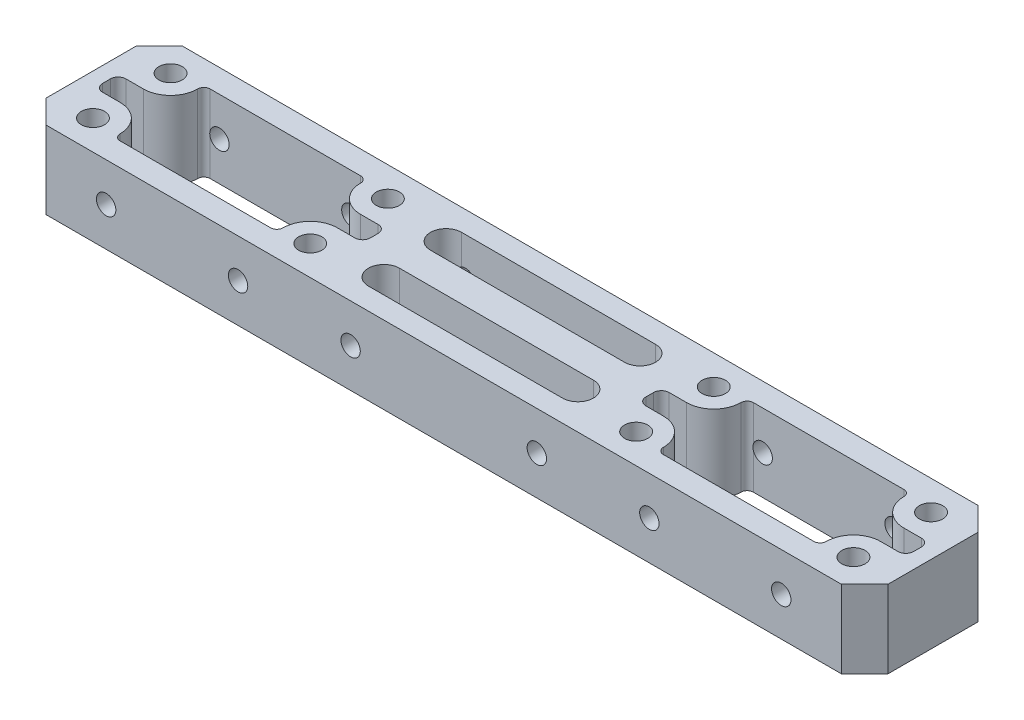
from build123d import *

# Parameters (mm, degrees)
SKETCH_1_W          = 38.5
SKETCH_1_H          = 17.6
SKETCH_1_R          = 1.5
EXTRUDE_1_DEPTH     = 10
CUT_EXTRUDE_1_DEPTH = 11
SKETCH_5_W          = 38.5
SKETCH_5_H          = 17.6
SKETCH_5_R          = 1.5
EXTRUDE_6_DEPTH     = 10
SKETCH_10_W         = 31.5
SKETCH_10_H         = 17.6
EXTRUDE_7_DEPTH     = 10
CUT_EXTRUDE_5_DEPTH = 11
CUT_EXTRUDE_6_DEPTH = 11
CHAMFER_1_SIZE      = 3
CUT_EXTRUDE_8_REACH = 19.6
SKETCH_14_R         = 1.25
CUT_EXTRUDE_9_REACH = 19.6
SKETCH_15_R         = 1.25


with BuildPart() as part:
    # 草图1 → 凸台-拉伸1 (new body)
    with BuildSketch(Plane(origin=(0, 0, 0), x_dir=(1, 0, 0), z_dir=(0, 1, 0))):
        Rectangle(SKETCH_1_W, SKETCH_1_H)
        with Locations((-14, 5)):
            Circle(SKETCH_1_R, mode=Mode.SUBTRACT)
        with Locations((-14, -5)):
            Circle(SKETCH_1_R, mode=Mode.SUBTRACT)
        with Locations((14, -5)):
            Circle(SKETCH_1_R, mode=Mode.SUBTRACT)
        with Locations((14, 5)):
            Circle(SKETCH_1_R, mode=Mode.SUBTRACT)
    extrude(amount=EXTRUDE_1_DEPTH)

    # 草图2 → 切除-拉伸1 (cut, through all)
    with BuildSketch(Plane(origin=(0, 10, 0), x_dir=(1, 0, 0), z_dir=(0, 1, 0))):
        with BuildLine():
            Line((9.7, 5.8), (-9.7, 5.8))
            ThreePointArc((-9.7, 5.8), (-10.265685425, 5.565685425), (-10.5, 5))
            ThreePointArc((-10.5, 5), (-11.525126266, 2.525126266), (-14, 1.5))
            Line((-14, 1.5), (-16.25, 1.5))
            ThreePointArc((-16.25, 1.5), (-16.957106781, 1.207106781), (-17.25, 0.5))
            Line((-17.25, 0.5), (-17.25, -0.5))
            ThreePointArc((-17.25, -0.5), (-16.957106781, -1.207106781), (-16.25, -1.5))
            Line((-16.25, -1.5), (-14, -1.5))
            ThreePointArc((-14, -1.5), (-11.525126266, -2.525126266), (-10.5, -5))
            ThreePointArc((-10.5, -5), (-10.265685425, -5.565685425), (-9.7, -5.8))
            Line((-9.7, -5.8), (9.7, -5.8))
            ThreePointArc((9.7, -5.8), (10.265685425, -5.565685425), (10.5, -5))
            ThreePointArc((10.5, -5), (11.525126266, -2.525126266), (14, -1.5))
            Line((14, -1.5), (16.25, -1.5))
            ThreePointArc((16.25, -1.5), (16.957106781, -1.207106781), (17.25, -0.5))
            Line((17.25, -0.5), (17.25, 0.5))
            ThreePointArc((17.25, 0.5), (16.957106781, 1.207106781), (16.25, 1.5))
            Line((16.25, 1.5), (14, 1.5))
            ThreePointArc((14, 1.5), (11.525126266, 2.525126266), (10.5, 5))
            ThreePointArc((10.5, 5), (10.265685425, 5.565685425), (9.7, 5.8))
        make_face()
    extrude(amount=-CUT_EXTRUDE_1_DEPTH, mode=Mode.SUBTRACT)



with BuildPart() as body_2:
    # 草图5 → 凸台-拉伸6 (new body)
    with BuildSketch(Plane(origin=(0, 10, 0), x_dir=(1, 0, 0), z_dir=(0, 1, 0))):
        with Locations((70, 0)):
            Rectangle(SKETCH_5_W, SKETCH_5_H)
        with Locations((56, 5)):
            Circle(SKETCH_5_R, mode=Mode.SUBTRACT)
        with Locations((84, 5)):
            Circle(SKETCH_5_R, mode=Mode.SUBTRACT)
        with Locations((84, -5)):
            Circle(SKETCH_5_R, mode=Mode.SUBTRACT)
        with Locations((56, -5)):
            Circle(SKETCH_5_R, mode=Mode.SUBTRACT)
    extrude(amount=-EXTRUDE_6_DEPTH)


with BuildPart() as part_1:
    add(part.part)

    add(body_2.part)  # 凸台-拉伸7 merges body 2
    # 草图10 → 凸台-拉伸7 (add)
    with BuildSketch(Plane(origin=(0, 10, 0), x_dir=(1, 0, 0), z_dir=(0, 1, 0))):
        with Locations((35, 0)):
            Rectangle(SKETCH_10_W, SKETCH_10_H)
    extrude(amount=-EXTRUDE_7_DEPTH)

    # 草图11 → 切除-拉伸5 (cut, through all)
    with BuildSketch(Plane(origin=(0, 10, 0), x_dir=(1, 0, 0), z_dir=(0, 1, 0))):
        with BuildLine():
            Line((16.25, 1.5), (14, 1.5))
            ThreePointArc((14, 1.5), (11.525126266, 2.525126266), (10.5, 5))
            ThreePointArc((10.5, 5), (10.265685425, 5.565685425), (9.7, 5.8))
            Line((9.7, 5.8), (-9.7, 5.8))
            ThreePointArc((-9.7, 5.8), (-10.265685425, 5.565685425), (-10.5, 5))
            ThreePointArc((-10.5, 5), (-11.525126266, 2.525126266), (-14, 1.5))
            Line((-14, 1.5), (-16.25, 1.5))
            ThreePointArc((-16.25, 1.5), (-16.957106781, 1.207106781), (-17.25, 0.5))
            Line((-17.25, 0.5), (-17.25, -0.5))
            ThreePointArc((-17.25, -0.5), (-16.957106781, -1.207106781), (-16.25, -1.5))
            Line((-16.25, -1.5), (-14, -1.5))
            ThreePointArc((-14, -1.5), (-11.525126266, -2.525126266), (-10.5, -5))
            ThreePointArc((-10.5, -5), (-10.265685425, -5.565685425), (-9.7, -5.8))
            Line((-9.7, -5.8), (9.7, -5.8))
            ThreePointArc((9.7, -5.8), (10.265685425, -5.565685425), (10.5, -5))
            ThreePointArc((10.5, -5), (11.525126266, -2.525126266), (14, -1.5))
            Line((14, -1.5), (16.25, -1.5))
            ThreePointArc((16.25, -1.5), (16.957106781, -1.207106781), (17.25, -0.5))
            Line((17.25, -0.5), (17.25, 0.5))
            ThreePointArc((17.25, 0.5), (16.957106781, 1.207106781), (16.25, 1.5))
        make_face()
        with BuildLine():
            Line((53.75, 1.5), (56, 1.5))
            ThreePointArc((56, 1.5), (58.474873734, 2.525126266), (59.5, 5))
            ThreePointArc((59.5, 5), (59.734314575, 5.565685425), (60.3, 5.8))
            Line((60.3, 5.8), (79.7, 5.8))
            ThreePointArc((79.7, 5.8), (80.265685425, 5.565685425), (80.5, 5))
            ThreePointArc((80.5, 5), (81.525126266, 2.525126266), (84, 1.5))
            Line((84, 1.5), (86.25, 1.5))
            ThreePointArc((86.25, 1.5), (86.957106781, 1.207106781), (87.25, 0.5))
            Line((87.25, 0.5), (87.25, -0.5))
            ThreePointArc((87.25, -0.5), (86.957106781, -1.207106781), (86.25, -1.5))
            Line((86.25, -1.5), (84, -1.5))
            ThreePointArc((84, -1.5), (81.525126266, -2.525126266), (80.5, -5))
            ThreePointArc((80.5, -5), (80.265685425, -5.565685425), (79.7, -5.8))
            Line((79.7, -5.8), (60.3, -5.8))
            ThreePointArc((60.3, -5.8), (59.734314575, -5.565685425), (59.5, -5))
            ThreePointArc((59.5, -5), (58.474873734, -2.525126266), (56, -1.5))
            Line((56, -1.5), (53.75, -1.5))
            ThreePointArc((53.75, -1.5), (53.042893219, -1.207106781), (52.75, -0.5))
            Line((52.75, -0.5), (52.75, 0.5))
            ThreePointArc((52.75, 0.5), (53.042893219, 1.207106781), (53.75, 1.5))
        make_face()
    extrude(amount=-CUT_EXTRUDE_5_DEPTH, mode=Mode.SUBTRACT)

    # 草图12 → 切除-拉伸6 (cut, through all)
    with BuildSketch(Plane(origin=(0, 10, 0), x_dir=(1, 0, 0), z_dir=(0, 1, 0))):
        with BuildLine():
            Line((22.5, 6), (47.5, 6))
            ThreePointArc((47.5, 6), (49.5, 4), (47.5, 2))
            Line((47.5, 2), (22.5, 2))
            ThreePointArc((22.5, 2), (20.5, 4), (22.5, 6))
        make_face()
        with BuildLine():
            Line((22.5, -6), (47.5, -6))
            ThreePointArc((47.5, -6), (49.5, -4), (47.5, -2))
            Line((47.5, -2), (22.5, -2))
            ThreePointArc((22.5, -2), (20.5, -4), (22.5, -6))
        make_face()
    extrude(amount=-CUT_EXTRUDE_6_DEPTH, mode=Mode.SUBTRACT)

    # 倒角1
    chamfer_1_edges = [part_1.edges().sort_by_distance(p)[0] for p in [
        (89.25, 5, 8.8),
        (89.25, 5, -8.8),
        (-19.25, 5, 8.8),
        (-19.25, 5, -8.8),
    ]]
    chamfer(chamfer_1_edges, length=CHAMFER_1_SIZE)

    # 草图14 → 切除-拉伸8 (cut, up to next)
    with BuildSketch(Plane(origin=(0, 0, -8.8), x_dir=(-1, 0, 0), z_dir=(0, 0, -1)), mode=Mode.PRIVATE) as cut_extrude_8_sk1:
        with Locations((-47, 5)):
            Circle(SKETCH_14_R)
    cut_extrude_8_tool1 = extrude(cut_extrude_8_sk1.sketch, amount=-CUT_EXTRUDE_8_REACH, mode=Mode.PRIVATE) & part_1.part
    add(cut_extrude_8_tool1.solids().sort_by_distance((47, 5, -8.8))[0], mode=Mode.SUBTRACT)
    # 草图14 → 切除-拉伸8 (cut, up to next)
    with BuildSketch(Plane(origin=(0, 0, -8.8), x_dir=(-1, 0, 0), z_dir=(0, 0, -1)), mode=Mode.PRIVATE) as cut_extrude_8_sk2:
        with Locations((-78.5, 5)):
            Circle(SKETCH_14_R)
    cut_extrude_8_tool2 = extrude(cut_extrude_8_sk2.sketch, amount=-CUT_EXTRUDE_8_REACH, mode=Mode.PRIVATE) & part_1.part
    add(cut_extrude_8_tool2.solids().sort_by_distance((78.5, 5, -8.8))[0], mode=Mode.SUBTRACT)
    # 草图14 → 切除-拉伸8 (cut, up to next)
    with BuildSketch(Plane(origin=(0, 0, -8.8), x_dir=(-1, 0, 0), z_dir=(0, 0, -1)), mode=Mode.PRIVATE) as cut_extrude_8_sk3:
        with Locations((-61.5, 5)):
            Circle(SKETCH_14_R)
    cut_extrude_8_tool3 = extrude(cut_extrude_8_sk3.sketch, amount=-CUT_EXTRUDE_8_REACH, mode=Mode.PRIVATE) & part_1.part
    add(cut_extrude_8_tool3.solids().sort_by_distance((61.5, 5, -8.8))[0], mode=Mode.SUBTRACT)
    # 草图14 → 切除-拉伸8 (cut, up to next)
    with BuildSketch(Plane(origin=(0, 0, -8.8), x_dir=(-1, 0, 0), z_dir=(0, 0, -1)), mode=Mode.PRIVATE) as cut_extrude_8_sk4:
        with Locations((-23, 5)):
            Circle(SKETCH_14_R)
    cut_extrude_8_tool4 = extrude(cut_extrude_8_sk4.sketch, amount=-CUT_EXTRUDE_8_REACH, mode=Mode.PRIVATE) & part_1.part
    add(cut_extrude_8_tool4.solids().sort_by_distance((23, 5, -8.8))[0], mode=Mode.SUBTRACT)
    # 草图14 → 切除-拉伸8 (cut, up to next)
    with BuildSketch(Plane(origin=(0, 0, -8.8), x_dir=(-1, 0, 0), z_dir=(0, 0, -1)), mode=Mode.PRIVATE) as cut_extrude_8_sk5:
        with Locations((-8.5, 5)):
            Circle(SKETCH_14_R)
    cut_extrude_8_tool5 = extrude(cut_extrude_8_sk5.sketch, amount=-CUT_EXTRUDE_8_REACH, mode=Mode.PRIVATE) & part_1.part
    add(cut_extrude_8_tool5.solids().sort_by_distance((8.5, 5, -8.8))[0], mode=Mode.SUBTRACT)
    # 草图14 → 切除-拉伸8 (cut, up to next)
    with BuildSketch(Plane(origin=(0, 0, -8.8), x_dir=(-1, 0, 0), z_dir=(0, 0, -1)), mode=Mode.PRIVATE) as cut_extrude_8_sk6:
        with Locations((8.5, 5)):
            Circle(SKETCH_14_R)
    cut_extrude_8_tool6 = extrude(cut_extrude_8_sk6.sketch, amount=-CUT_EXTRUDE_8_REACH, mode=Mode.PRIVATE) & part_1.part
    add(cut_extrude_8_tool6.solids().sort_by_distance((-8.5, 5, -8.8))[0], mode=Mode.SUBTRACT)

    # 草图15 → 切除-拉伸9 (cut, up to next)
    with BuildSketch(Plane.XY.offset(8.8), mode=Mode.PRIVATE) as cut_extrude_9_sk1:
        with Locations((-8.5, 5)):
            Circle(SKETCH_15_R)
    cut_extrude_9_tool1 = extrude(cut_extrude_9_sk1.sketch, amount=-CUT_EXTRUDE_9_REACH, mode=Mode.PRIVATE) & part_1.part
    add(cut_extrude_9_tool1.solids().sort_by_distance((-8.5, 5, 8.8))[0], mode=Mode.SUBTRACT)
    # 草图15 → 切除-拉伸9 (cut, up to next)
    with BuildSketch(Plane.XY.offset(8.8), mode=Mode.PRIVATE) as cut_extrude_9_sk2:
        with Locations((8.5, 5)):
            Circle(SKETCH_15_R)
    cut_extrude_9_tool2 = extrude(cut_extrude_9_sk2.sketch, amount=-CUT_EXTRUDE_9_REACH, mode=Mode.PRIVATE) & part_1.part
    add(cut_extrude_9_tool2.solids().sort_by_distance((8.5, 5, 8.8))[0], mode=Mode.SUBTRACT)
    # 草图15 → 切除-拉伸9 (cut, up to next)
    with BuildSketch(Plane.XY.offset(8.8), mode=Mode.PRIVATE) as cut_extrude_9_sk3:
        with Locations((23, 5)):
            Circle(SKETCH_15_R)
    cut_extrude_9_tool3 = extrude(cut_extrude_9_sk3.sketch, amount=-CUT_EXTRUDE_9_REACH, mode=Mode.PRIVATE) & part_1.part
    add(cut_extrude_9_tool3.solids().sort_by_distance((23, 5, 8.8))[0], mode=Mode.SUBTRACT)
    # 草图15 → 切除-拉伸9 (cut, up to next)
    with BuildSketch(Plane.XY.offset(8.8), mode=Mode.PRIVATE) as cut_extrude_9_sk4:
        with Locations((47, 5)):
            Circle(SKETCH_15_R)
    cut_extrude_9_tool4 = extrude(cut_extrude_9_sk4.sketch, amount=-CUT_EXTRUDE_9_REACH, mode=Mode.PRIVATE) & part_1.part
    add(cut_extrude_9_tool4.solids().sort_by_distance((47, 5, 8.8))[0], mode=Mode.SUBTRACT)
    # 草图15 → 切除-拉伸9 (cut, up to next)
    with BuildSketch(Plane.XY.offset(8.8), mode=Mode.PRIVATE) as cut_extrude_9_sk5:
        with Locations((61.5, 5)):
            Circle(SKETCH_15_R)
    cut_extrude_9_tool5 = extrude(cut_extrude_9_sk5.sketch, amount=-CUT_EXTRUDE_9_REACH, mode=Mode.PRIVATE) & part_1.part
    add(cut_extrude_9_tool5.solids().sort_by_distance((61.5, 5, 8.8))[0], mode=Mode.SUBTRACT)
    # 草图15 → 切除-拉伸9 (cut, up to next)
    with BuildSketch(Plane.XY.offset(8.8), mode=Mode.PRIVATE) as cut_extrude_9_sk6:
        with Locations((78.5, 5)):
            Circle(SKETCH_15_R)
    cut_extrude_9_tool6 = extrude(cut_extrude_9_sk6.sketch, amount=-CUT_EXTRUDE_9_REACH, mode=Mode.PRIVATE) & part_1.part
    add(cut_extrude_9_tool6.solids().sort_by_distance((78.5, 5, 8.8))[0], mode=Mode.SUBTRACT)


solid = part_1.part
